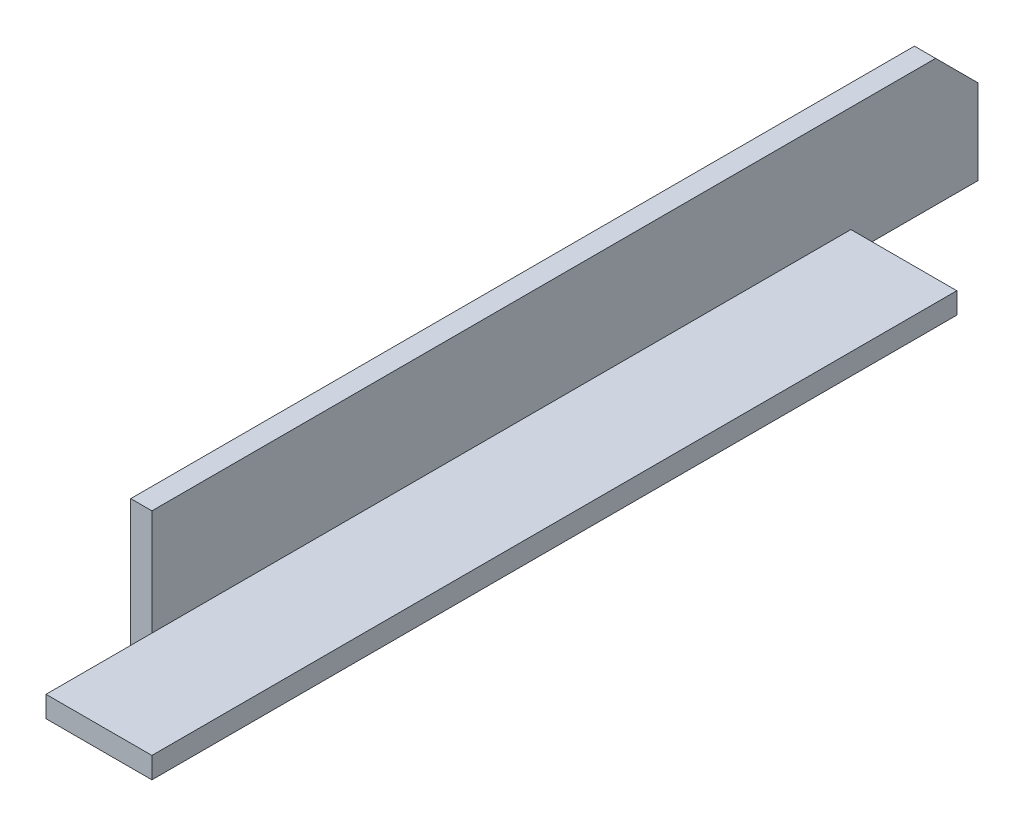
from build123d import *

# Parameters (mm, degrees)
BOSS_EXTRUDE1_DEPTH = 279.4
SKETCH2_W           = 31.75
SKETCH2_H           = 38.1
CUT_EXTRUDE1_DEPTH  = 6.35
SKETCH3_W           = 31.75
SKETCH3_H           = 38.1
CUT_EXTRUDE2_DEPTH  = 39.1
CUT_EXTRUDE3_DEPTH  = 39.1


with BuildPart() as part:
    # Sketch1 → Boss-Extrude1 (new body)
    with BuildSketch(Plane.XY):
        Polygon((0, 0), (0, 38.1), (6.35, 38.1), (6.35, 6.35), (38.1, 6.35), (38.1, 0), align=None)
    extrude(amount=BOSS_EXTRUDE1_DEPTH)

    # Sketch2 → Cut-Extrude1 (cut)
    with BuildSketch(Plane.ZY):
        with Locations((263.525, 19.05)):
            Rectangle(SKETCH2_W, SKETCH2_H)
    extrude(amount=-CUT_EXTRUDE1_DEPTH, mode=Mode.SUBTRACT)

    # Sketch3 → Cut-Extrude2 (cut, through all)
    with BuildSketch(Plane.XZ):
        with Locations((22.225, 19.05)):
            Rectangle(SKETCH3_W, SKETCH3_H)
    extrude(amount=-CUT_EXTRUDE2_DEPTH, mode=Mode.SUBTRACT)

    # Sketch4 → Cut-Extrude3 (cut, through all)
    with BuildSketch(Plane.ZY):
        Polygon((0, 38.1), (0, 25.4), (12.7, 38.1), align=None)
    extrude(amount=-CUT_EXTRUDE3_DEPTH, mode=Mode.SUBTRACT)


solid = part.part
